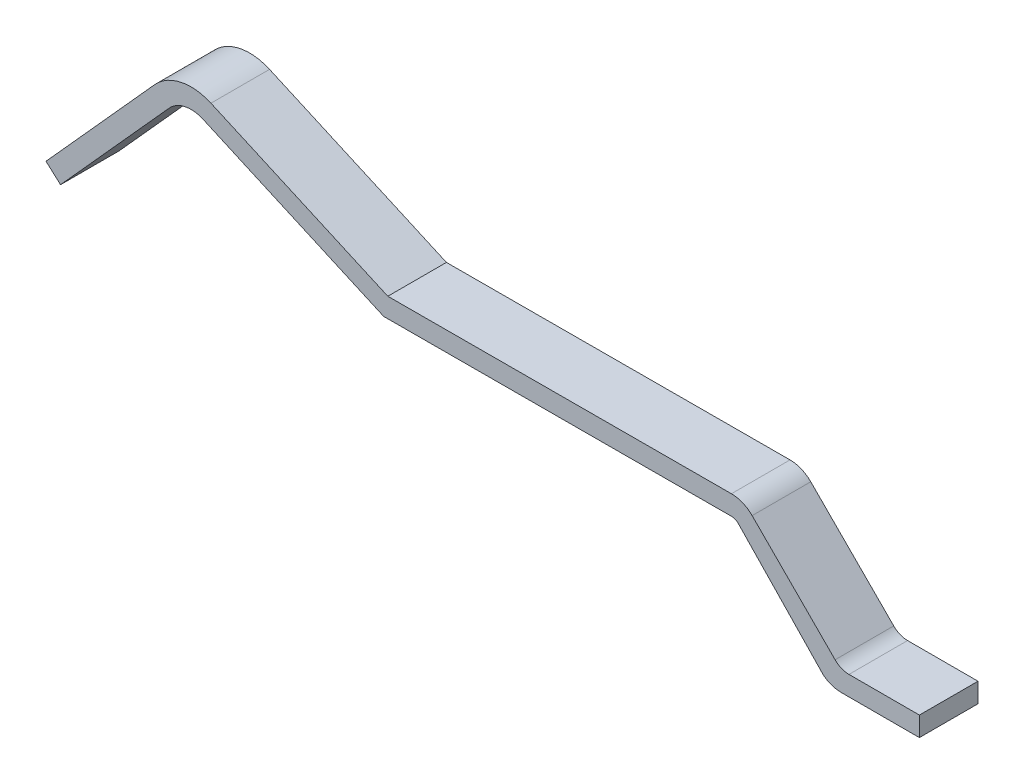
from build123d import *

# Parameters (mm, degrees)
RESSALTO_EXTRUS_O1_DEPTH = 0.3


with BuildPart() as part:
    # Esboço1 → Ressalto-extrusão1 (new body, symmetric)
    with BuildSketch(Plane.XY):
        with BuildLine():
            Line((17.891752756, 0.197947805), (17.891752756, -0.002052195))
            Line((17.891752756, -0.002052195), (17.091752756, -0.002052195))
            ThreePointArc((17.091752756, -0.002052195), (16.996884427, 0.013342816), (16.911752756, 0.057947805))
            Line((16.911752756, 0.057947805), (16.038199366, 0.968756691))
            ThreePointArc((16.038199366, 0.968756691), (16.005773821, 0.990473944), (15.967488688, 0.99804386))
            Line((15.967488688, 0.99804386), (12.407488688, 0.99))
            Line((12.407488688, 0.99), (10.557971552, 1.813458083))
            ThreePointArc((10.557971552, 1.813458083), (10.373577052, 1.832838725), (10.213007112, 1.740133627))
            Line((10.213007112, 1.740133627), (9.099531826, 0.503494039))
            Line((9.099531826, 0.503494039), (8.95090286, 0.637320161))
            Line((8.95090286, 0.637320161), (10.064378147, 1.873959748))
            ThreePointArc((10.064378147, 1.873959748), (10.331994714, 2.028468246), (10.639318881, 1.996167174))
            Line((10.639318881, 1.996167174), (12.45, 1.19))
            Line((12.45, 1.19), (15.967488688, 1.197947805))
            ThreePointArc((15.967488688, 1.197947805), (16.082345327, 1.175236263), (16.179620722, 1.11007984))
            Line((16.179620722, 1.11007984), (17.029007121, 0.256846352))
            ThreePointArc((17.029007121, 0.256846352), (17.094002269, 0.213258484), (17.170747658, 0.197947805))
            Line((17.170747658, 0.197947805), (17.891752756, 0.197947805))
        make_face()
    extrude(amount=RESSALTO_EXTRUS_O1_DEPTH, both=True)


solid = part.part
